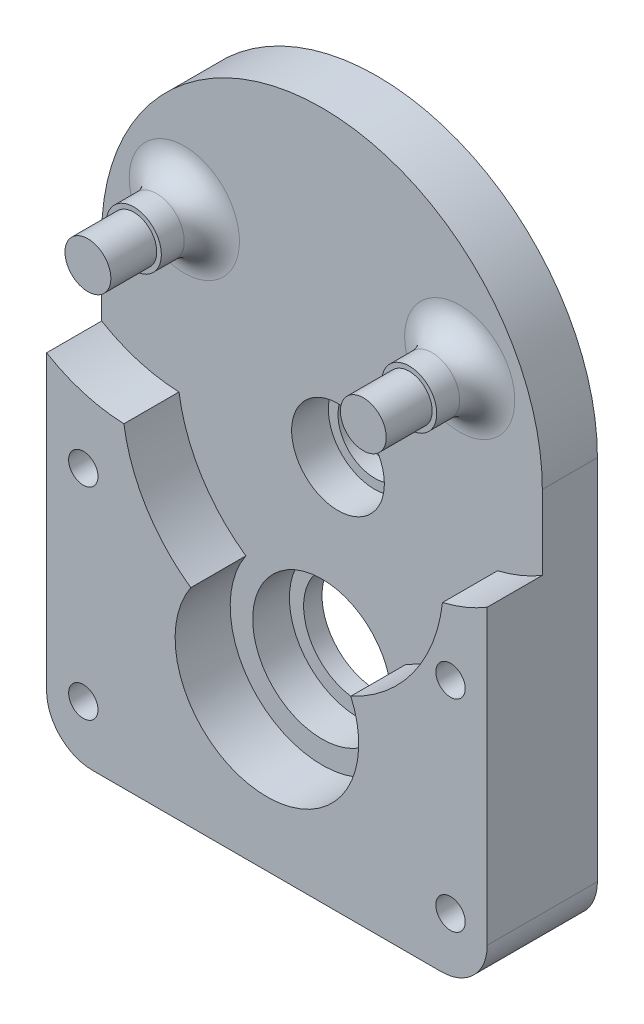
from build123d import *

# Parameters (mm, degrees)
EXTRUDE_1_DEPTH     = 6
SKETCH_3_R          = 3
EXTRUDE_2_DEPTH     = 5.5
SKETCH_4_R          = 2.5
EXTRUDE_3_DEPTH     = 5
SKETCH_5_R          = 5.05
CUT_EXTRUDE_1_DEPTH = 4
SKETCH_6_R          = 4
CUT_EXTRUDE_2_DEPTH = 3
SKETCH_7_R          = 7.55
CUT_EXTRUDE_3_DEPTH = 4
SKETCH_8_R          = 6
CUT_EXTRUDE_4_DEPTH = 3
FILLET_1_R          = 3
EXTRUDE_4_DEPTH     = 6
SKETCH_10_R         = 1.6
CUT_EXTRUDE_5_DEPTH = 17.5
SKETCH_11_R         = 2.1
CUT_EXTRUDE_6_DEPTH = 6
FILLET_2_R          = 5


with BuildPart() as part:
    # 草图1 → 凸台-拉伸1 (new body)
    with BuildSketch(Plane.XY):
        with BuildLine():
            Line((-24, 0), (-24, -45))
            Line((-24, -45), (24, -45))
            Line((24, -45), (24, 0))
            ThreePointArc((24, 0), (0, 24), (-24, 0))
        make_face()
    extrude(amount=EXTRUDE_1_DEPTH)

    # 草图3 → 凸台-拉伸2 (add)
    with BuildSketch(Plane.XY.offset(6)):
        with Locations((-15, 6.899039913)):
            Circle(SKETCH_3_R)
        with Locations((15, 6.899039913)):
            Circle(SKETCH_3_R)
    extrude(amount=EXTRUDE_2_DEPTH)

    # 草图4 → 凸台-拉伸3 (add)
    with BuildSketch(Plane.XY.offset(11.5)):
        with Locations((-15, 6.899039913)):
            Circle(SKETCH_4_R)
        with Locations((15, 6.899039913)):
            Circle(SKETCH_4_R)
    extrude(amount=EXTRUDE_3_DEPTH)

    # 草图5 → 切除-拉伸1 (cut)
    with BuildSketch(Plane.XY.offset(6)):
        with Locations((1.743114855, -8.076106038)):
            Circle(SKETCH_5_R)
    extrude(amount=-CUT_EXTRUDE_1_DEPTH, mode=Mode.SUBTRACT)

    # 草图6 → 切除-拉伸2 (cut, through all)
    with BuildSketch(Plane.XY.offset(2)):
        with Locations((1.743114855, -8.076106038)):
            Circle(SKETCH_6_R)
    extrude(amount=-CUT_EXTRUDE_2_DEPTH, mode=Mode.SUBTRACT)

    # 草图7 → 切除-拉伸3 (cut)
    with BuildSketch(Plane.XY.offset(6)):
        with Locations((0, -28)):
            Circle(SKETCH_7_R)
    extrude(amount=-CUT_EXTRUDE_3_DEPTH, mode=Mode.SUBTRACT)

    # 草图8 → 切除-拉伸4 (cut, through all)
    with BuildSketch(Plane.XY.offset(2)):
        with Locations((0, -28)):
            Circle(SKETCH_8_R)
    extrude(amount=-CUT_EXTRUDE_4_DEPTH, mode=Mode.SUBTRACT)

    # 圆角1
    fillet_1_edges = [part.edges().sort_by_distance(p)[0] for p in [
        (-18, 6.899039913, 6),
        (12, 6.899039913, 6),
    ]]
    fillet(fillet_1_edges, radius=FILLET_1_R)

    # 草图9 → 凸台-拉伸4 (add)
    with BuildSketch(Plane.XY.offset(6)):
        with BuildLine():
            Line((24, -45), (24, -8.109291107))
            ThreePointArc((24, -8.109291107), (21.638033238, -9.293134578), (19.124765434, -10.107908964))
            ThreePointArc((19.124765434, -10.107908964), (15.930250057, -18.32184636), (9.137474346, -23.93717308))
            ThreePointArc((9.137474346, -23.93717308), (-0.871557427, -37.961946981), (-8.293153088, -22.412190782))
            ThreePointArc((-8.293153088, -22.412190782), (-13.156547867, -17.254888679), (-15.575163477, -10.591505733))
            ThreePointArc((-15.575163477, -10.591505733), (-19.945835244, -9.887523575), (-24, -8.109291107))
            Line((-24, -8.109291107), (-24, -45))
            Line((-24, -45), (24, -45))
        make_face()
    extrude(amount=EXTRUDE_4_DEPTH)

    # 草图10 → 切除-拉伸5 (cut, through all)
    with BuildSketch(Plane(origin=(0, 0, 0), x_dir=(-1, 0, 0), z_dir=(0, 0, -1))):
        with Locations((-20, -39)):
            Circle(SKETCH_10_R)
        with Locations((-20, -17)):
            Circle(SKETCH_10_R)
        with Locations((20, -39)):
            Circle(SKETCH_10_R)
        with Locations((20, -17)):
            Circle(SKETCH_10_R)
    extrude(amount=-CUT_EXTRUDE_5_DEPTH, mode=Mode.SUBTRACT)

    # 草图11 → 切除-拉伸6 (cut)
    with BuildSketch(Plane(origin=(0, 0, 0), x_dir=(-1, 0, 0), z_dir=(0, 0, -1))):
        with Locations((-20, -17)):
            Circle(SKETCH_11_R)
        with Locations((-20, -39)):
            Circle(SKETCH_11_R)
        with Locations((20, -17)):
            Circle(SKETCH_11_R)
        with Locations((20, -39)):
            Circle(SKETCH_11_R)
    extrude(amount=-CUT_EXTRUDE_6_DEPTH, mode=Mode.SUBTRACT)

    # 圆角2
    fillet_2_edges = [part.edges().sort_by_distance(p)[0] for p in [
        (24, -45, 6),
        (-24, -45, 6),
    ]]
    fillet(fillet_2_edges, radius=FILLET_2_R)


solid = part.part
